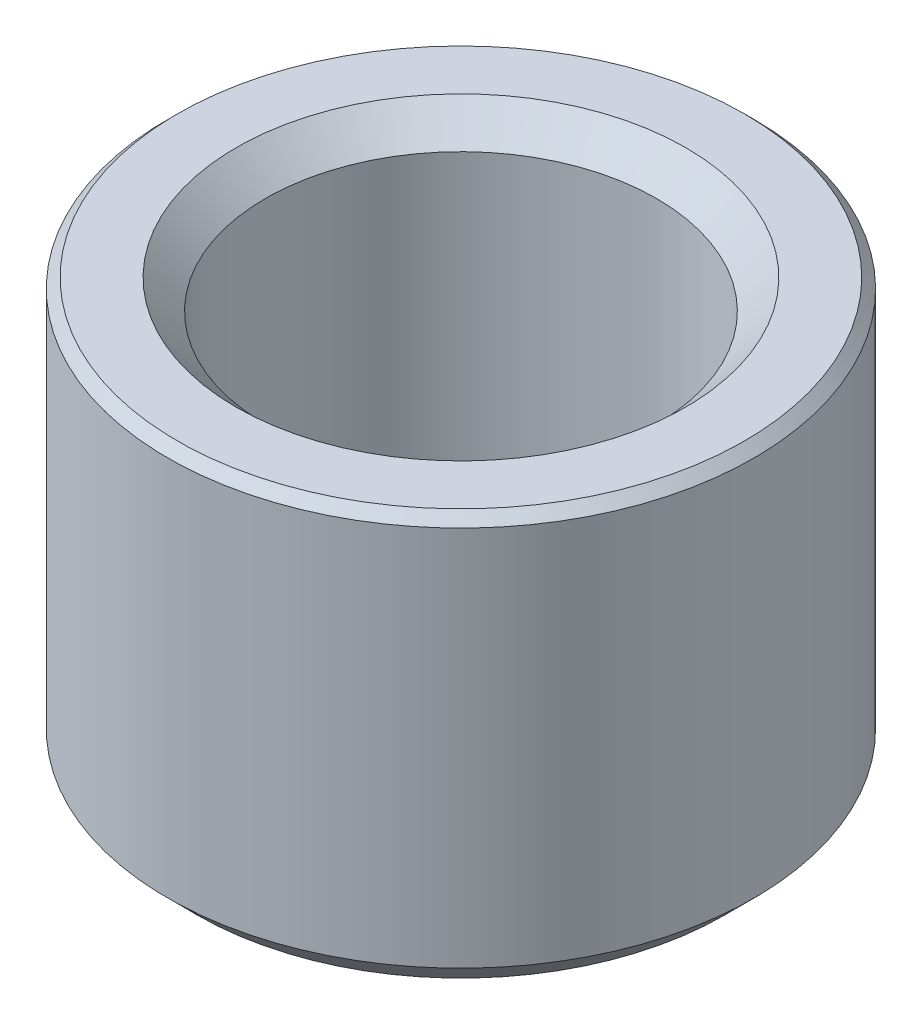
from build123d import *


with BuildPart() as part:
    # Sketch1 → Revolve1 (revolve)
    with BuildSketch(Plane.XY):
        Polygon((-1.35, 0), (-0.65, 0), (-0.5, 0.15), (-1, 0.45043031), (-1, 2), (-1.15, 2.15), (-1.45, 2.15), (-1.5, 2.1), (-1.5, 0.15), align=None)
    revolve(axis=Axis((0, -0.7027378, 0), (0, 1, 0)))


solid = part.part
